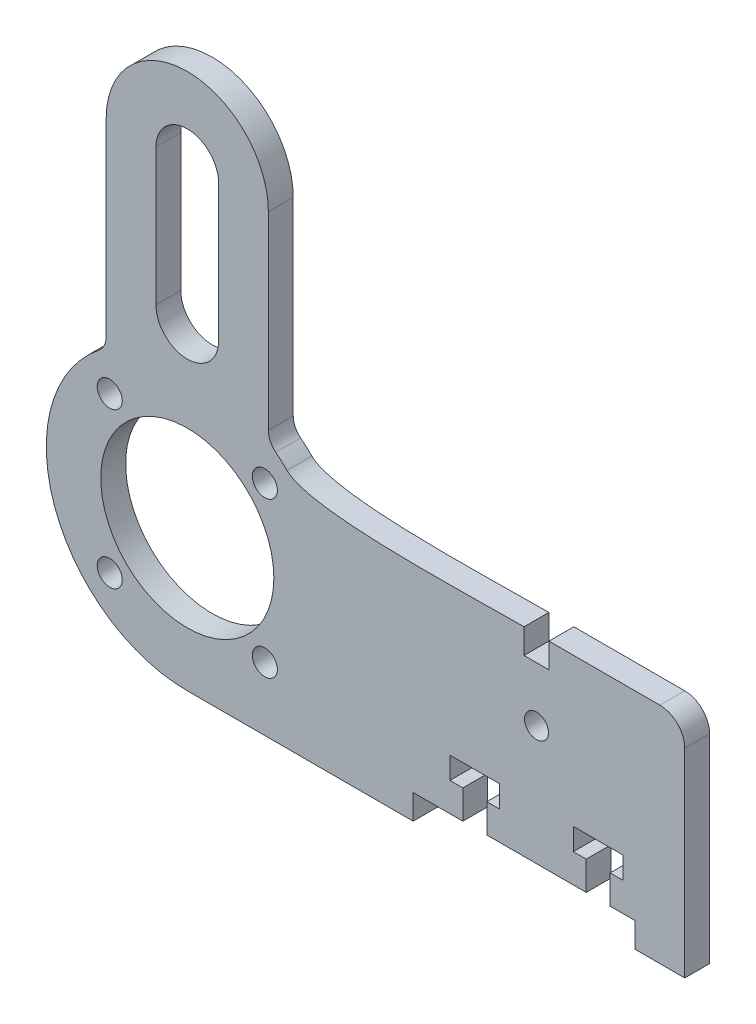
from build123d import *

# Parameters (mm, degrees)
SKETCH1_R           = 11.049
SKETCH1_R_2         = 1.6
SKETCH1_R_3         = 1.524
BOSS_EXTRUDE1_DEPTH = 3.175


with BuildPart() as part:
    # Sketch1 → Boss-Extrude1 (new body)
    with BuildSketch(Plane.XY):
        with BuildLine():
            Line((57.15, -17.99971), (63.5, -17.99971))
            Line((63.5, -17.99971), (63.5, 7.40029))
            ThreePointArc((63.5, 7.40029), (62.57006403, 9.64535403), (60.325, 10.57529))
            Line((60.325, 10.57529), (46.1645, 10.57529))
            Line((46.1645, 10.57529), (46.1645, 7.40029))
            Line((46.1645, 7.40029), (42.9895, 7.40029))
            Line((42.9895, 7.40029), (42.9895, 10.57529))
            add(Edge.make_bspline(
                [(12.727717, 12.727717), (15.734639389, 9.720794612), (35.054158727, 10.57529), (42.9895, 10.57529)],
                knots=[0, 0, 0, 0, 1, 1, 1, 1], degree=3))
            ThreePointArc((12.727717, 12.727717), (12.029263941, 13.389786), (11.296423453, 14.013578318))
            ThreePointArc((11.296423453, 14.013578318), (10.59915166, 14.89503307), (10.3505, 15.991081784))
            Line((10.3505, 15.991081784), (10.3505, 40.126055474))
            ThreePointArc((10.3505, 40.126055474), (0, 50.476555474), (-10.3505, 40.126055474))
            Line((-10.3505, 40.126055474), (-10.3505, 15.991081784))
            ThreePointArc((-10.3505, 15.991081784), (-10.59915166, 14.89503307), (-11.296423453, 14.013578318))
            ThreePointArc((-11.296423453, 14.013578318), (-16.973949244, -5.989541481), (0, -17.99971))
            Line((0, -17.99971), (28.829, -17.99971))
            Line((28.829, -17.99971), (28.829, -14.82471))
            Line((28.829, -14.82471), (35.179, -14.82471))
            Line((35.179, -14.82471), (35.179, -11.14171))
            Line((35.179, -11.14171), (33.528, -11.14171))
            Line((33.528, -11.14171), (33.528, -8.34771))
            Line((33.528, -8.34771), (39.878, -8.34771))
            Line((39.878, -8.34771), (39.878, -11.14171))
            Line((39.878, -11.14171), (38.227, -11.14171))
            Line((38.227, -11.14171), (38.227, -14.82471))
            Line((38.227, -14.82471), (50.927, -14.82471))
            Line((50.927, -14.82471), (50.927, -11.14171))
            Line((50.927, -11.14171), (49.276, -11.14171))
            Line((49.276, -11.14171), (49.276, -8.34771))
            Line((49.276, -8.34771), (55.626, -8.34771))
            Line((55.626, -8.34771), (55.626, -11.14171))
            Line((55.626, -11.14171), (53.975, -11.14171))
            Line((53.975, -11.14171), (53.975, -14.82471))
            Line((53.975, -14.82471), (57.15, -14.82471))
            Line((57.15, -14.82471), (57.15, -17.99971))
        make_face()
        Circle(SKETCH1_R, mode=Mode.SUBTRACT)
        with Locations((9.899834348, 9.899834348)):
            Circle(SKETCH1_R_2, mode=Mode.SUBTRACT)
        with Locations((9.899834348, -9.899834348)):
            Circle(SKETCH1_R_2, mode=Mode.SUBTRACT)
        with Locations((-9.899834348, -9.899834348)):
            Circle(SKETCH1_R_2, mode=Mode.SUBTRACT)
        with Locations((-9.899834348, 9.899834348)):
            Circle(SKETCH1_R_2, mode=Mode.SUBTRACT)
        with Locations((44.577, 0.41529)):
            Circle(SKETCH1_R_3, mode=Mode.SUBTRACT)
        with BuildLine():
            Line((4.0005, 40.126055474), (4.0005, 22.664731685))
            ThreePointArc((4.0005, 22.664731685), (0, 18.664231685), (-4.0005, 22.664731685))
            Line((-4.0005, 22.664731685), (-4.0005, 40.126055474))
            ThreePointArc((-4.0005, 40.126055474), (0, 44.126555474), (4.0005, 40.126055474))
        make_face(mode=Mode.SUBTRACT)
    extrude(amount=BOSS_EXTRUDE1_DEPTH)


solid = part.part
